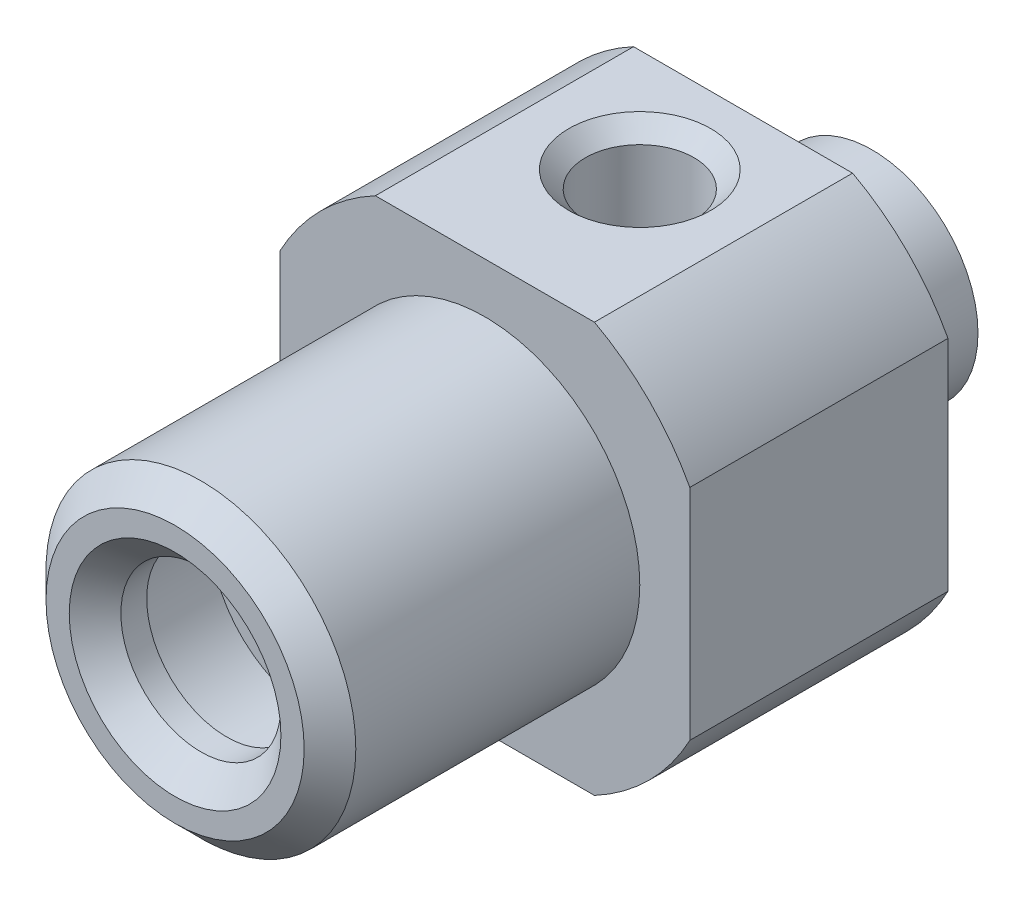
from build123d import *

# Parameters (mm, degrees)
CUT_EXTRUDE2_REACH              = 24
M5X0_8_TAPPED_HOLE1_D           = 4.2
M5X0_8_TAPPED_HOLE1_DEPTH       = 7
M5X0_8_TAPPED_HOLE1_CSINK_D     = 5.5
M5X0_8_TAPPED_HOLE1_CSINK_ANGLE = 90


with BuildPart() as part:
    # Sketch1 → Revolve1 (revolve)
    with BuildSketch(Plane(origin=(0, 0, 0), x_dir=(0, 0, -1), z_dir=(1, 0, 0))):
        Polygon((-12.5, 3.1), (-13.5, 4.1), (-13.5, 5), (-12.5, 6), (-1.5, 6), (-1.5, 9), (8.5, 9), (8.5, 4.75), (9.85, 4.75), (9.85, 4.1), (13.5, 4.1), (13.5, 2.25), (-8, 2.25), (-8, 4.15), (-11.5, 4.15), (-11.5, 3.1), align=None)
    revolve(axis=Axis((0, 0, 0), (0, 0, -1)))

    # Sketch2 → Cut-Extrude2 (cut, up to next)
    with BuildSketch(Plane(origin=(0, 0, -8.5), x_dir=(-1, 0, 0), z_dir=(0, 0, -1)), mode=Mode.PRIVATE) as cut_extrude2_sk1:
        with BuildLine():
            ThreePointArc((4.242180306, 7.9375), (0, 9), (-4.242180306, 7.9375))
            Line((-4.242180306, 7.9375), (4.242180306, 7.9375))
        make_face()
    cut_extrude2_tool1 = extrude(cut_extrude2_sk1.sketch, amount=-CUT_EXTRUDE2_REACH, mode=Mode.PRIVATE) & part.part
    add(cut_extrude2_tool1.solids().sort_by_distance((0, 8.364726, -8.5))[0], mode=Mode.SUBTRACT)
    # Sketch2 → Cut-Extrude2 (cut, up to next)
    with BuildSketch(Plane(origin=(0, 0, -8.5), x_dir=(-1, 0, 0), z_dir=(0, 0, -1)), mode=Mode.PRIVATE) as cut_extrude2_sk2:
        with BuildLine():
            Line((-7.9375, -4.242180306), (-7.9375, 4.242180306))
            ThreePointArc((-7.9375, 4.242180306), (-9, 0), (-7.9375, -4.242180306))
        make_face()
    cut_extrude2_tool2 = extrude(cut_extrude2_sk2.sketch, amount=-CUT_EXTRUDE2_REACH, mode=Mode.PRIVATE) & part.part
    add(cut_extrude2_tool2.solids().sort_by_distance((8.364726, 0, -8.5))[0], mode=Mode.SUBTRACT)
    # Sketch2 → Cut-Extrude2 (cut, up to next)
    with BuildSketch(Plane(origin=(0, 0, -8.5), x_dir=(-1, 0, 0), z_dir=(0, 0, -1)), mode=Mode.PRIVATE) as cut_extrude2_sk3:
        with BuildLine():
            Line((4.242180306, -7.9375), (-4.242180306, -7.9375))
            ThreePointArc((-4.242180306, -7.9375), (0, -9), (4.242180306, -7.9375))
        make_face()
    cut_extrude2_tool3 = extrude(cut_extrude2_sk3.sketch, amount=-CUT_EXTRUDE2_REACH, mode=Mode.PRIVATE) & part.part
    add(cut_extrude2_tool3.solids().sort_by_distance((0, -8.364726, -8.5))[0], mode=Mode.SUBTRACT)
    # Sketch2 → Cut-Extrude2 (cut, up to next)
    with BuildSketch(Plane(origin=(0, 0, -8.5), x_dir=(-1, 0, 0), z_dir=(0, 0, -1)), mode=Mode.PRIVATE) as cut_extrude2_sk4:
        with BuildLine():
            ThreePointArc((9, 0), (8.730335045, 2.186606961), (7.9375, 4.242180306))
            Line((7.9375, 4.242180306), (7.9375, -4.242180306))
            ThreePointArc((7.9375, -4.242180306), (8.730335045, -2.186606961), (9, 0))
        make_face()
    cut_extrude2_tool4 = extrude(cut_extrude2_sk4.sketch, amount=-CUT_EXTRUDE2_REACH, mode=Mode.PRIVATE) & part.part
    add(cut_extrude2_tool4.solids().sort_by_distance((-8.364726, 0, -8.5))[0], mode=Mode.SUBTRACT)

    # M5x0.8 Tapped Hole1
    with Locations(Plane(origin=(0, 7.9375, 0), x_dir=(1, 0, 0), z_dir=(0, 1, 0))):
        with Locations((0, 4.5)):
            CounterSinkHole(M5X0_8_TAPPED_HOLE1_D / 2, M5X0_8_TAPPED_HOLE1_CSINK_D / 2, depth=M5X0_8_TAPPED_HOLE1_DEPTH, counter_sink_angle=M5X0_8_TAPPED_HOLE1_CSINK_ANGLE)


solid = part.part
